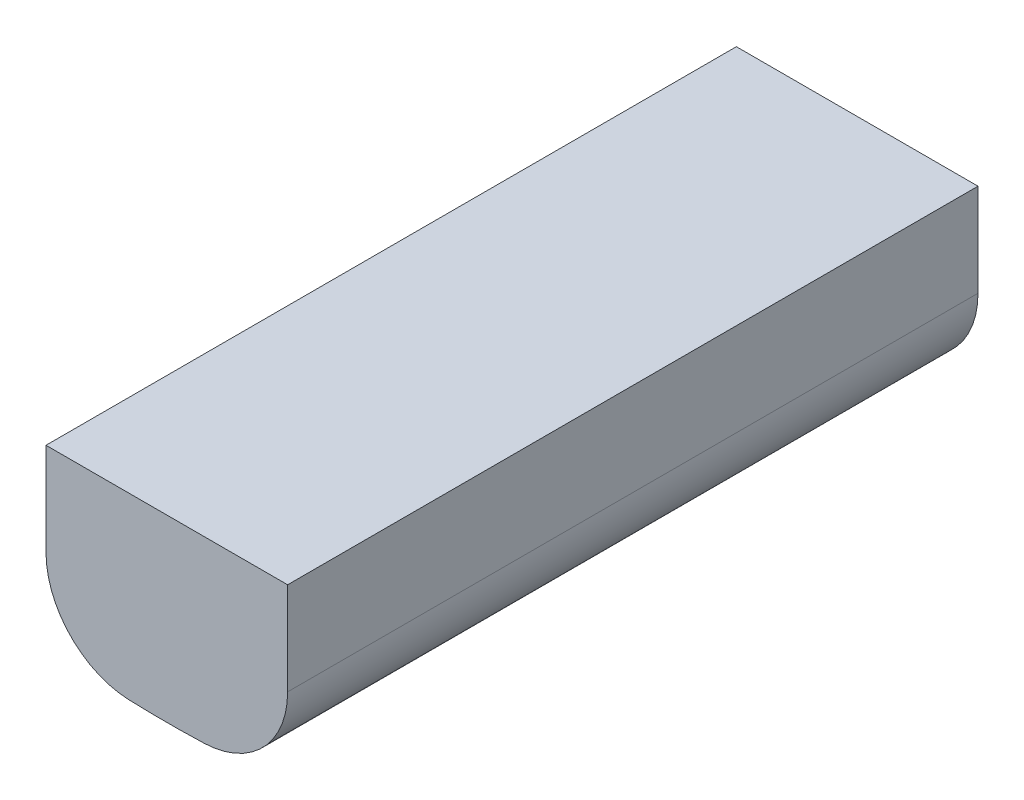
from build123d import *

# Parameters (mm, degrees)
SALIENTE_EXTRUIR1_DEPTH = 1


with BuildPart() as part:
    # Croquis1 → Saliente-Extruir1 (new body)
    with BuildSketch(Plane.XY):
        with BuildLine():
            Line((-0.175, -1.239756692), (0.175, -1.239756692))
            Line((0.175, -1.239756692), (0.175, -1.374090608))
            ThreePointArc((0.175, -1.374090608), (0.139981059, -1.460857014), (0.054545455, -1.499007936))
            ThreePointArc((0.054545455, -1.499007936), (0, -1.5), (-0.054545455, -1.499007936))
            ThreePointArc((-0.054545455, -1.499007936), (-0.139981059, -1.460857014), (-0.175, -1.374090608))
            Line((-0.175, -1.374090608), (-0.175, -1.239756692))
        make_face()
    extrude(amount=SALIENTE_EXTRUIR1_DEPTH)


solid = part.part
